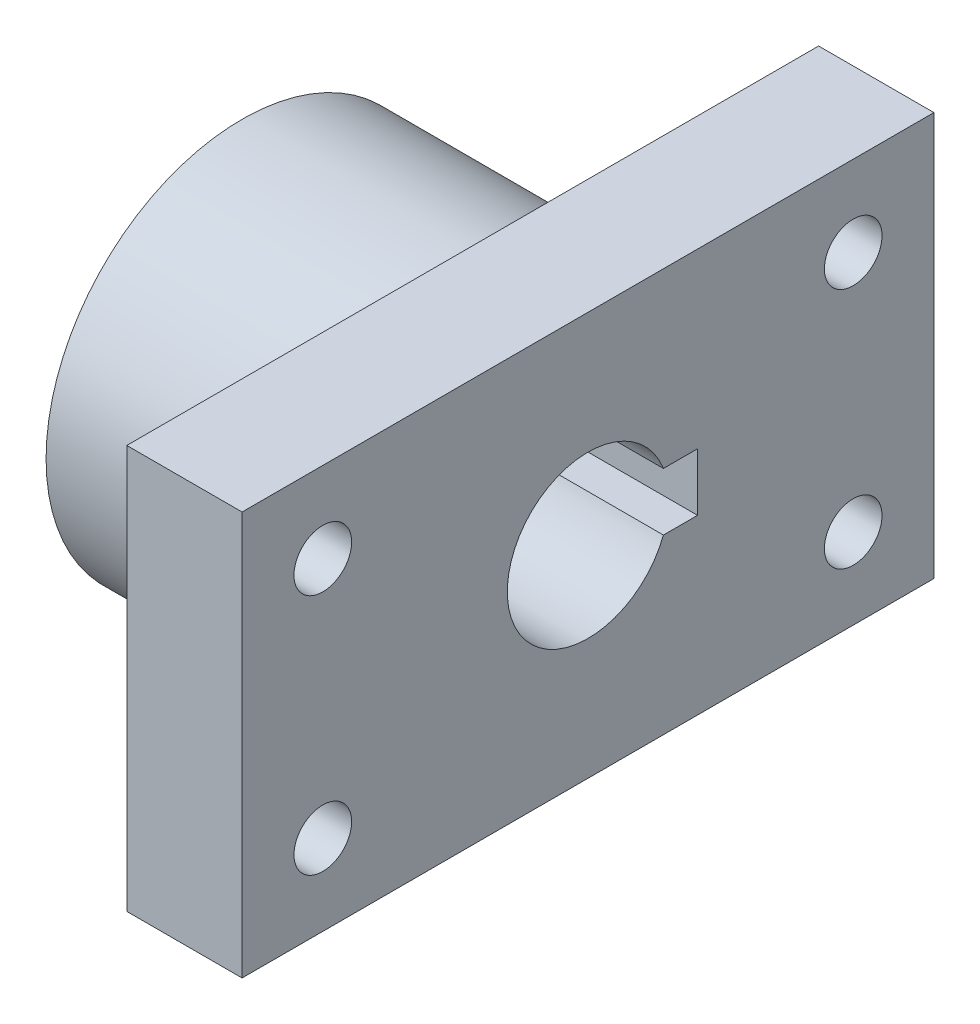
from build123d import *

# Parameters (mm, degrees)
SKETCH1_W                = 60
SKETCH1_H                = 35
BOSS_EXTRUDE1_DEPTH      = 30
CUT_EXTRUDE1_DEPTH       = 31
F_5_0_5_DIAMETER_HOLE1_D = 5
SKETCH6_W                = 60
SKETCH6_H                = 35
SKETCH6_R                = 17
CUT_EXTRUDE2_DEPTH       = 20


with BuildPart() as part:
    # Sketch1 → Boss-Extrude1 (new body)
    with BuildSketch(Plane(origin=(0, 0, 0), x_dir=(0, 0, -1), z_dir=(1, 0, 0))):
        Rectangle(SKETCH1_W, SKETCH1_H)
    extrude(amount=BOSS_EXTRUDE1_DEPTH)

    # Sketch2 → Cut-Extrude1 (cut, through all)
    with BuildSketch(Plane(origin=(30, 0, 0), x_dir=(0, 0, -1), z_dir=(1, 0, 0))):
        with BuildLine():
            Line((4.5, 2.5), (4.5, -2.5))
            Line((4.5, -2.5), (6.538348415, -2.5))
            ThreePointArc((6.538348415, -2.5), (6.883619648, -1.271133567), (7, 0))
            ThreePointArc((7, 0), (6.883619648, 1.271133567), (6.538348415, 2.5))
            Line((6.538348415, 2.5), (4.5, 2.5))
        make_face()
        with BuildLine():
            Line((6.538348415, -2.5), (4.5, -2.5))
            Line((4.5, -2.5), (4.5, 2.5))
            Line((4.5, 2.5), (6.538348415, 2.5))
            ThreePointArc((6.538348415, 2.5), (-7, 0), (6.538348415, -2.5))
        make_face()
        with BuildLine():
            ThreePointArc((7, 0), (6.883619648, -1.271133567), (6.538348415, -2.5))
            Line((6.538348415, -2.5), (9.5, -2.5))
            Line((9.5, -2.5), (9.5, 2.5))
            Line((9.5, 2.5), (6.538348415, 2.5))
            ThreePointArc((6.538348415, 2.5), (6.883619648, 1.271133567), (7, 0))
        make_face()
    extrude(amount=-CUT_EXTRUDE1_DEPTH, mode=Mode.SUBTRACT)

    # Ø5.0 (5) Diameter Hole1 (through all)
    with Locations(Plane.ZY):
        with Locations((-23, 10.5), (-23, -10.5)):
            f_5_0_5_diameter_hole1 = Hole(F_5_0_5_DIAMETER_HOLE1_D / 2)

    # Mirror1: Ø5.0 (5) Diameter Hole1 across plane
    add(f_5_0_5_diameter_hole1.mirror(Plane.XY), mode=Mode.SUBTRACT)

    # Sketch6 → Cut-Extrude2 (cut)
    with BuildSketch(Plane.ZY):
        Rectangle(SKETCH6_W, SKETCH6_H)
        Circle(SKETCH6_R, mode=Mode.SUBTRACT)
    extrude(amount=-CUT_EXTRUDE2_DEPTH, mode=Mode.SUBTRACT)


solid = part.part
